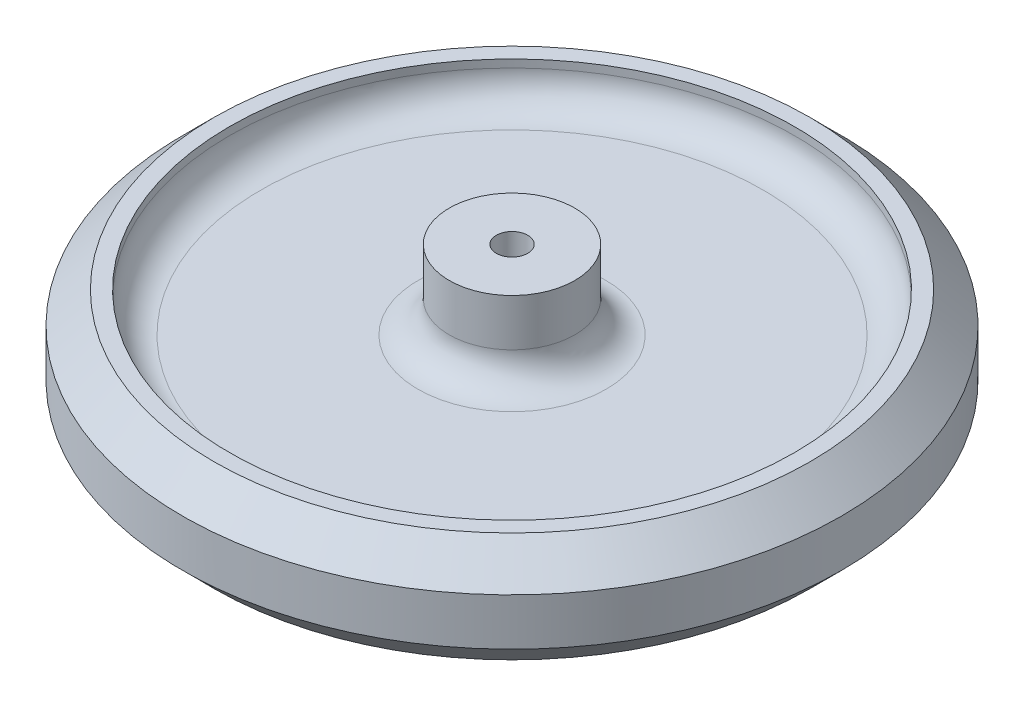
from build123d import *

# Parameters (mm, degrees)
FILLET1_R     = 3.175
CHAMFER1_SIZE = 3.175


with BuildPart() as part:
    # Sketch1 → Revolve1 (revolve)
    with BuildSketch(Plane.XY):
        Polygon((-6.35, 9.525), (-1.5875, 9.525), (-1.5875, -9.525), (-6.35, -9.525), (-6.35, -1.5875), (-28.575, -1.5875), (-28.575, -5.55625), (-33.3375, -5.55625), (-33.3375, 5.55625), (-28.575, 5.55625), (-28.575, 1.5875), (-6.35, 1.5875), align=None)
    revolve(axis=Axis((0, -9.525, 0), (0, 1, 0)))

    # Fillet1
    fillet1_edges = [part.edges().sort_by_distance(p)[0] for p in [
        (28.575, -1.5875, 0),
        (6.35, -1.5875, 0),
        (6.35, 1.5875, 0),
        (28.575, 1.5875, 0),
    ]]
    fillet(fillet1_edges, radius=FILLET1_R)

    # Chamfer1
    chamfer1_edges = [part.edges().sort_by_distance(p)[0] for p in [
        (33.3375, 5.55625, 0),
        (33.3375, -5.55625, 0),
    ]]
    chamfer(chamfer1_edges, length=CHAMFER1_SIZE)


solid = part.part
